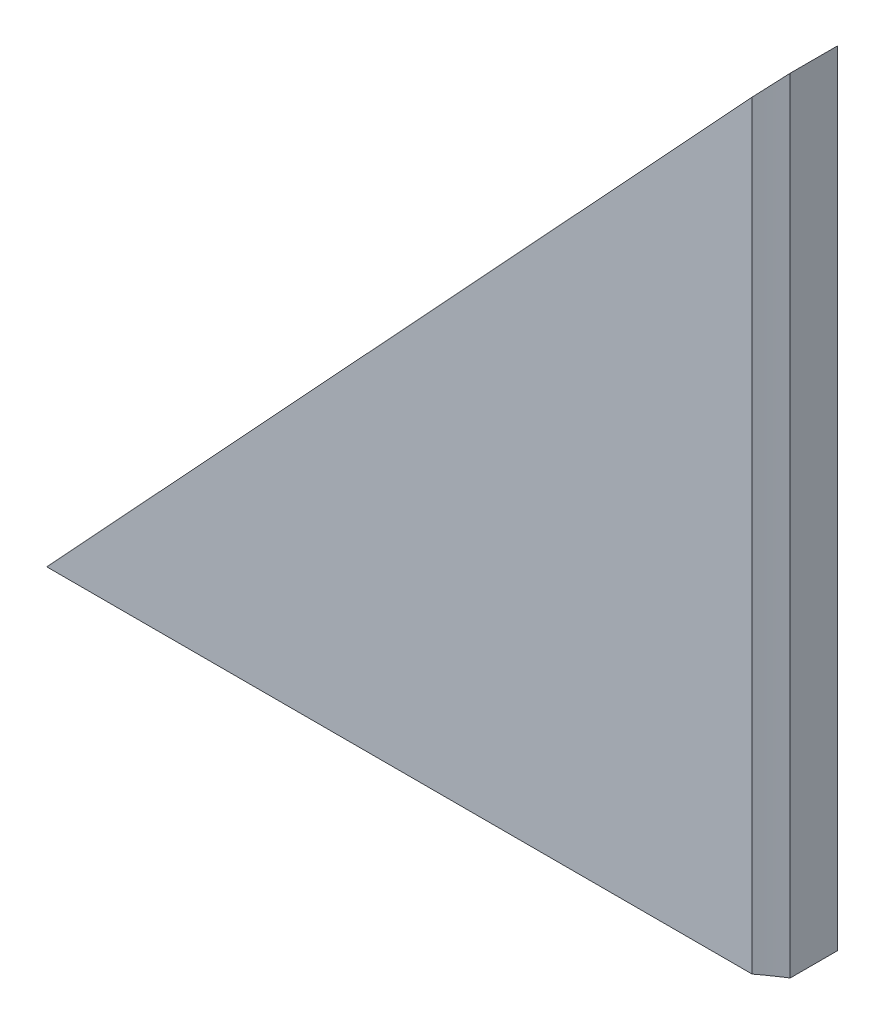
from build123d import *

# Parameters (mm, degrees)
DODANIE_WYCI_GNI_CIE1_DEPTH = 2
SZKIC2_R                    = 12.5
WYTNIJ_WYCI_GNI_CIE1_DEPTH  = 25


with BuildPart() as part:
    # Szkic1 → Dodanie-wyciągnięcie1 (new body)
    with BuildSketch(Plane(origin=(0, 0, -1.5), x_dir=(-1, 0, 0), z_dir=(0, 0, -1))):
        Polygon((23.22, 0), (0, 25), (0, 0), align=None)
    extrude(amount=-DODANIE_WYCI_GNI_CIE1_DEPTH)

    # Szkic2 → Wytnij-wyciągnięcie1 (cut)
    with BuildSketch(Plane(origin=(0, 0, 0), x_dir=(-1, 0, 0), z_dir=(0, -1, 0))):
        with Locations((-6.78, -10.501504654)):
            Circle(SZKIC2_R)
    extrude(amount=-WYTNIJ_WYCI_GNI_CIE1_DEPTH, mode=Mode.SUBTRACT)


solid = part.part
